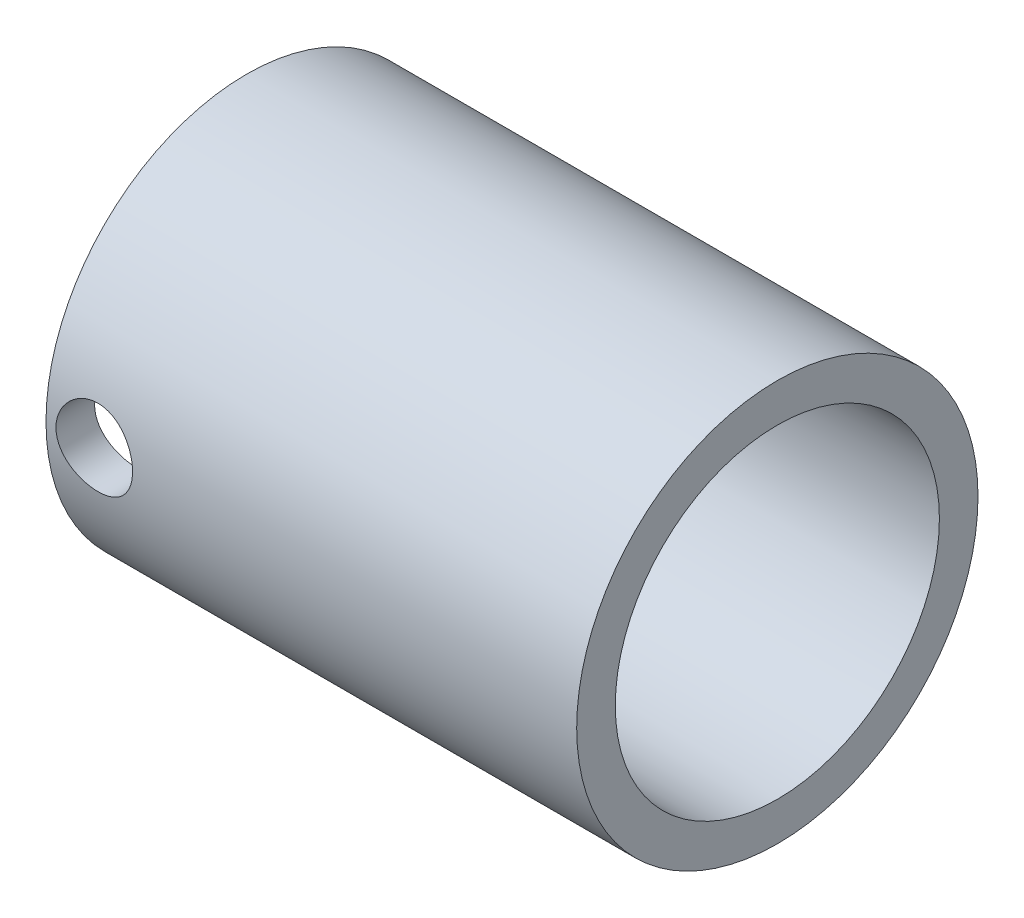
from build123d import *

# Parameters (mm, degrees)
CUT_EXTRUDE1_REACH = 18.637
SKETCH2_R          = 3.175


with BuildPart() as part:
    # Sketch1 → Revolve1 (revolve)
    with BuildSketch(Plane.XY):
        Polygon((-1.5875, -10.4648), (1.5875, -10.4648), (1.5875, -13.2842), (22, -13.4366), (22, -16.637), (-22, -16.637), (-22, -13.4366), (-1.5875, -13.2842), align=None)
    revolve(axis=Axis((-22, 0, 0), (1, 0, 0)))

    # Sketch2 → Cut-Extrude1 (cut, up to next)
    with BuildSketch(Plane.XY, mode=Mode.PRIVATE) as cut_extrude1_sk1:
        with Locations((-18, 0)):
            Circle(SKETCH2_R)
    cut_extrude1_tool1 = extrude(cut_extrude1_sk1.sketch, amount=CUT_EXTRUDE1_REACH, mode=Mode.PRIVATE) & part.part
    add(cut_extrude1_tool1.solids().sort_by_distance((-18, 0, 0))[0], mode=Mode.SUBTRACT)


solid = part.part
